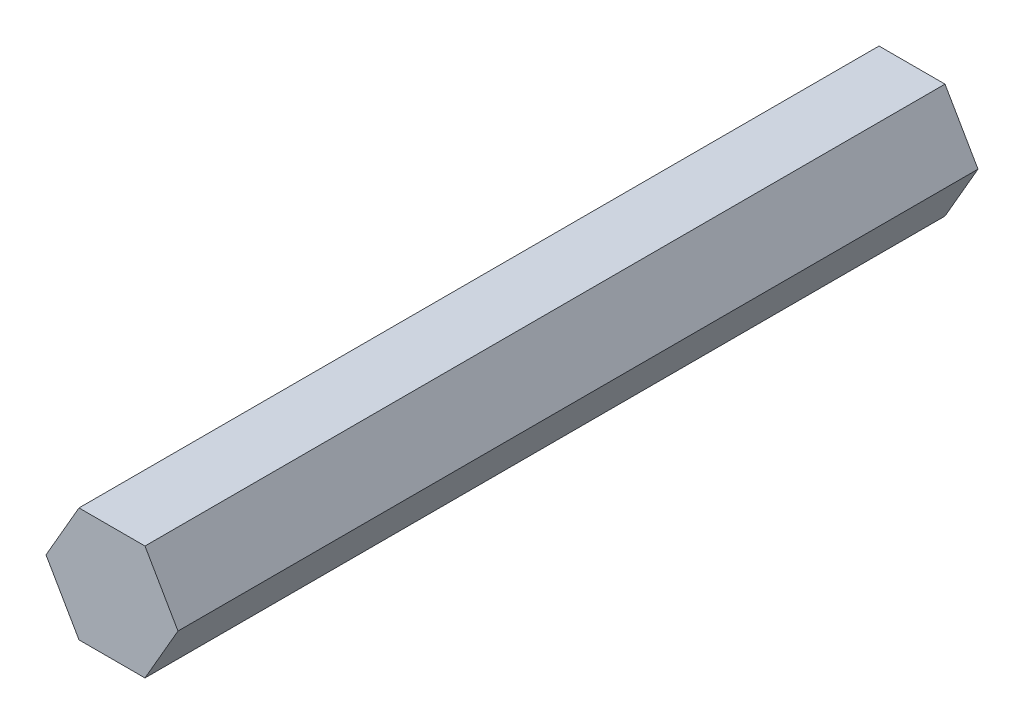
from build123d import *

# Parameters (mm, degrees)
BOSS_EXTRUDE1_DEPTH = 88.9


with BuildPart() as part:
    # Sketch1 → Boss-Extrude1 (new body)
    with BuildSketch(Plane.XY):
        Polygon((7.332348419, 0), (3.666174209, 6.35), (-3.666174209, 6.35), (-7.332348419, 0), (-3.666174209, -6.35), (3.666174209, -6.35), align=None)
    extrude(amount=BOSS_EXTRUDE1_DEPTH)


solid = part.part
